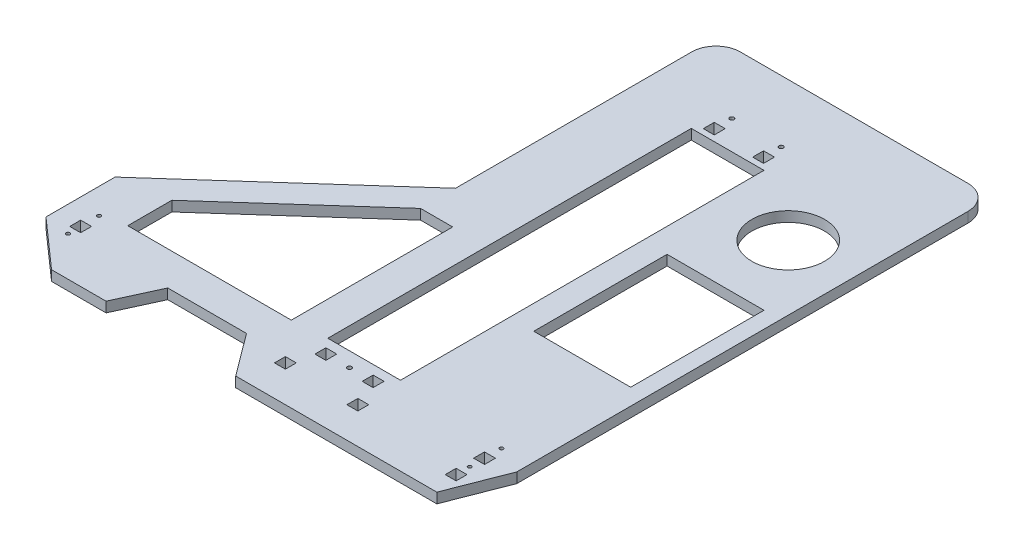
from build123d import *

# Parameters (mm, degrees)
BOSS_EXTRUDE1_DEPTH = 8.4
SKETCH2_R           = 1.5
SKETCH2_R_2         = 1.75
SKETCH2_W           = 60
SKETCH2_H           = 300
SKETCH2_W_2         = 9
SKETCH2_H_2         = 9
CUT_EXTRUDE1_DEPTH  = 9.4
FILLET1_R           = 20
SKETCH3_R           = 30
SKETCH3_W           = 80
SKETCH3_H           = 110
CUT_EXTRUDE2_DEPTH  = 9.4


with BuildPart() as part:
    # Sketch1 → Boss-Extrude1 (new body)
    with BuildSketch(Plane(origin=(0, 0, 0), x_dir=(1, 0, 0), z_dir=(0, 1, 0))):
        Polygon((0, 0), (-228, 0), (-228, -215), (-376.5, -347.47169509), (-376.5, -404.47169509), (-336.5, -439.9), (-291.5, -439.9), (-275.5, -405), (-210.5, -405), (-184.5, -439.9), (-18.5, -439.9), (0, -392.4), align=None)
    extrude(amount=BOSS_EXTRUDE1_DEPTH)

    # Sketch2 → Cut-Extrude1 (cut, through all)
    with BuildSketch(Plane(origin=(0, 8.4, 0), x_dir=(1, 0, 0), z_dir=(0, 1, 0))):
        with Locations((-23.1, -408.2)):
            Circle(SKETCH2_R)
        with Locations((-23.1, -382)):
            Circle(SKETCH2_R)
        with Locations((-355.4, -407.37169509)):
            Circle(SKETCH2_R)
        with Locations((-355.4, -381.77169509)):
            Circle(SKETCH2_R)
        with Locations((-163.85, -51.1)):
            Circle(SKETCH2_R_2)
        with Locations((-123.15, -51.1)):
            Circle(SKETCH2_R_2)
        with Locations((-143.5, -387)):
            Circle(SKETCH2_R_2)
        Polygon((-336.5, -340.600531429), (-228, -243.811447811), (-201.5, -243.811447811), (-201.5, -377), (-336.5, -377), align=None)
        with Locations((-143.5, -224.9)):
            Rectangle(SKETCH2_W, SKETCH2_H)
        with Locations((-23.1, -419.4)):
            Rectangle(SKETCH2_W_2, SKETCH2_H_2)
        with Locations((-23.1, -395.95)):
            Rectangle(SKETCH2_W_2, SKETCH2_H_2)
        with Locations((-355.4, -396.97169509)):
            Rectangle(SKETCH2_W_2, SKETCH2_H_2)
        with Locations((-163.85, -65.6)):
            Rectangle(SKETCH2_W_2, SKETCH2_H_2)
        with Locations((-123.15, -65.6)):
            Rectangle(SKETCH2_W_2, SKETCH2_H_2)
        with Locations((-163, -387)):
            Rectangle(SKETCH2_W_2, SKETCH2_H_2)
        with Locations((-124, -387)):
            Rectangle(SKETCH2_W_2, SKETCH2_H_2)
        with Locations((-173.4, -410)):
            Rectangle(SKETCH2_W_2, SKETCH2_H_2)
        with Locations((-113.6, -410)):
            Rectangle(SKETCH2_W_2, SKETCH2_H_2)
    extrude(amount=-CUT_EXTRUDE1_DEPTH, mode=Mode.SUBTRACT)

    # Fillet1
    fillet1_edges = [part.edges().sort_by_distance(p)[0] for p in [
        (-228, 4.2, 0),
        (0, 4.2, 0),
    ]]
    fillet(fillet1_edges, radius=FILLET1_R)

    # Sketch3 → Cut-Extrude2 (cut, through all)
    with BuildSketch(Plane(origin=(0, 8.4, 0), x_dir=(1, 0, 0), z_dir=(0, 1, 0))):
        with Locations((-53.5, -114.9)):
            Circle(SKETCH3_R)
        with Locations((-53.5, -229.9)):
            Rectangle(SKETCH3_W, SKETCH3_H)
    extrude(amount=-CUT_EXTRUDE2_DEPTH, mode=Mode.SUBTRACT)


solid = part.part
